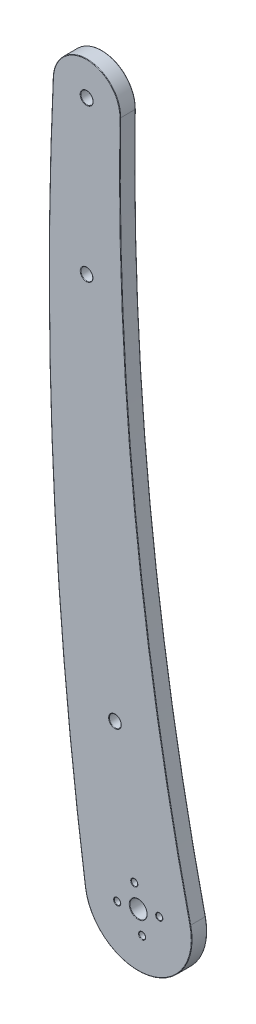
from build123d import *

# Parameters (mm, degrees)
SKETCH1_R           = 2.8
SKETCH1_R_2         = 2
SKETCH1_R_3         = 1.95
SKETCH1_R_4         = 1.05
BOSS_EXTRUDE1_DEPTH = 5
FILLET1_R           = 0.15


with BuildPart() as part:
    # Sketch1 → Boss-Extrude1 (new body)
    with BuildSketch(Plane.XY):
        with BuildLine():
            ThreePointArc((-26.079167388, 278.756611768), (-21.239110839, 169.437578513), (-3.167903279, 61.513954424))
            ThreePointArc((-3.167903279, 61.513954424), (-17.024180678, 40.374281798), (-37.547403455, 55.128247669))
            ThreePointArc((-37.547403455, 55.128247669), (-48.065680098, 167.044655833), (-48.065582127, 279.454248661))
            ThreePointArc((-48.065582127, 279.454248661), (-36.728796341, 289.933495141), (-26.079167388, 278.756611768))
        make_face()
        with Locations((-20.22, 57.58)):
            Circle(SKETCH1_R, mode=Mode.SUBTRACT)
        with Locations((-37.077654746, 278.93902845)):
            Circle(SKETCH1_R_2, mode=Mode.SUBTRACT)
        with Locations((-37.107397794, 228.939037297)):
            Circle(SKETCH1_R_3, mode=Mode.SUBTRACT)
        with Locations((-27.821012361, 106.998868978)):
            Circle(SKETCH1_R_3, mode=Mode.SUBTRACT)
        with Locations((-18.941672271, 50.697712719)):
            Circle(SKETCH1_R_4, mode=Mode.SUBTRACT)
        with Locations((-27.102287281, 56.301672271)):
            Circle(SKETCH1_R_4, mode=Mode.SUBTRACT)
        with Locations((-21.498327729, 64.462287281)):
            Circle(SKETCH1_R_4, mode=Mode.SUBTRACT)
        with Locations((-13.337712719, 58.858327729)):
            Circle(SKETCH1_R_4, mode=Mode.SUBTRACT)
    extrude(amount=-BOSS_EXTRUDE1_DEPTH)

    # Fillet1
    fillet1_edges = [part.edges().sort_by_distance(p)[0] for p in [
        (-23.02, 57.58, -5),
        (-23.02, 57.58, 0),
        (-17.024180678, 40.374281798, -5),
        (-39.077654746, 278.93902845, -5),
        (-39.077654746, 278.93902845, 0),
        (-21.239110839, 169.437578513, -5),
        (-29.771012361, 106.998868978, -5),
        (-29.771012361, 106.998868978, 0),
        (-39.057397794, 228.939037297, -5),
        (-39.057397794, 228.939037297, 0),
        (-19.991672271, 50.697712719, -5),
        (-19.991672271, 50.697712719, 0),
        (-28.152287281, 56.301672271, -5),
        (-28.152287281, 56.301672271, 0),
        (-22.548327729, 64.462287281, -5),
        (-22.548327729, 64.462287281, 0),
        (-14.387712719, 58.858327729, -5),
        (-14.387712719, 58.858327729, 0),
        (-36.728796341, 289.933495141, -5),
        (-21.239110839, 169.437578513, 0),
        (-17.024180678, 40.374281798, 0),
        (-48.065680098, 167.044655833, 0),
        (-36.728796341, 289.933495141, 0),
        (-48.065680098, 167.044655833, -5),
    ]]
    fillet(fillet1_edges, radius=FILLET1_R)


solid = part.part
